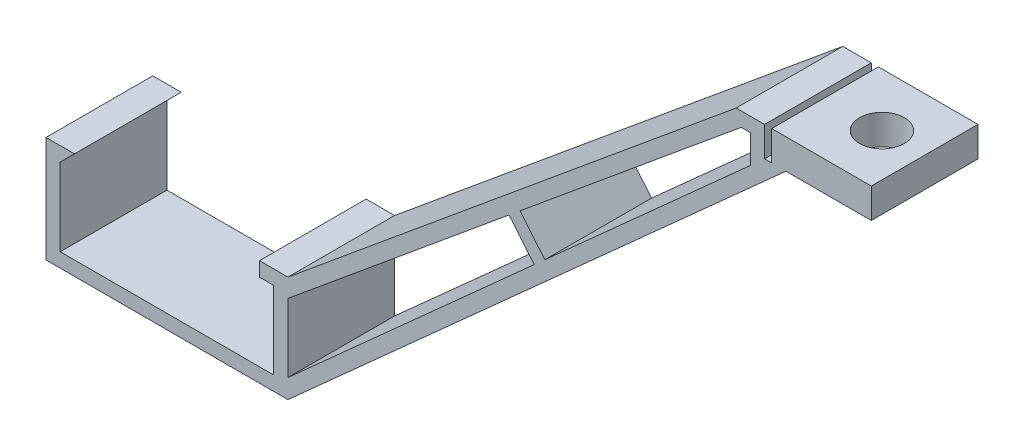
from build123d import *

# Parameters (mm, degrees)
BOSS_EXTRUDE1_DEPTH = 15
BOSS_EXTRUDE2_DEPTH = 15
SKETCH3_W           = 12
SKETCH3_H           = 4.2
BOSS_EXTRUDE3_DEPTH = 15
CUT_EXTRUDE1_REACH  = 69
SKETCH4_R           = 3.15


with BuildPart() as part:
    # Sketch1 → Boss-Extrude1 (new body)
    with BuildSketch(Plane.XY):
        Polygon((-15, -15), (-15, -4.085), (-13, -2.085), (-17, -2.085), (-17, -17), (17, -17), (17, -2.085), (13, -2.085), (13, -4.085), (15, -4.085), (15, -15), align=None)
    extrude(amount=BOSS_EXTRUDE1_DEPTH)

    # Sketch2 → Boss-Extrude2 (add)
    with BuildSketch(Plane(origin=(0, 0, 0), x_dir=(-1, 0, 0), z_dir=(0, 0, -1))):
        Polygon((-80, 50), (-17, -2.085), (-17, -4.68000212), (-48.089133488, 21.022815621), (-51.622859883, 16.748556949), (-17, -14.313094489), (-17, -17), (-87, 45.8), (-87, 50), (-85, 50), (-85, 45.8), (-84, 45.8), (-84, 50), align=None)
        Polygon((-80.719691535, 48), (-49.630558047, 22.297182259), (-53.112776785, 18.085225255), (-82, 44.001191225), (-82, 48), align=None, mode=Mode.SUBTRACT)
    extrude(amount=-BOSS_EXTRUDE2_DEPTH)

    # Sketch3 → Boss-Extrude3 (add)
    with BuildSketch(Plane(origin=(0, 0, 0), x_dir=(-1, 0, 0), z_dir=(0, 0, -1))):
        with Locations((-93, 47.9)):
            Rectangle(SKETCH3_W, SKETCH3_H)
    extrude(amount=-BOSS_EXTRUDE3_DEPTH)

    # Sketch4 → Cut-Extrude1 (cut, up to next)
    with BuildSketch(Plane(origin=(0, 50, 0), x_dir=(1, 0, 0), z_dir=(0, 1, 0)), mode=Mode.PRIVATE) as cut_extrude1_sk1:
        with Locations((93, -7.5)):
            Circle(SKETCH4_R)
    cut_extrude1_tool1 = extrude(cut_extrude1_sk1.sketch, amount=-CUT_EXTRUDE1_REACH, mode=Mode.PRIVATE) & part.part
    add(cut_extrude1_tool1.solids().sort_by_distance((93, 50, 7.5))[0], mode=Mode.SUBTRACT)


solid = part.part
